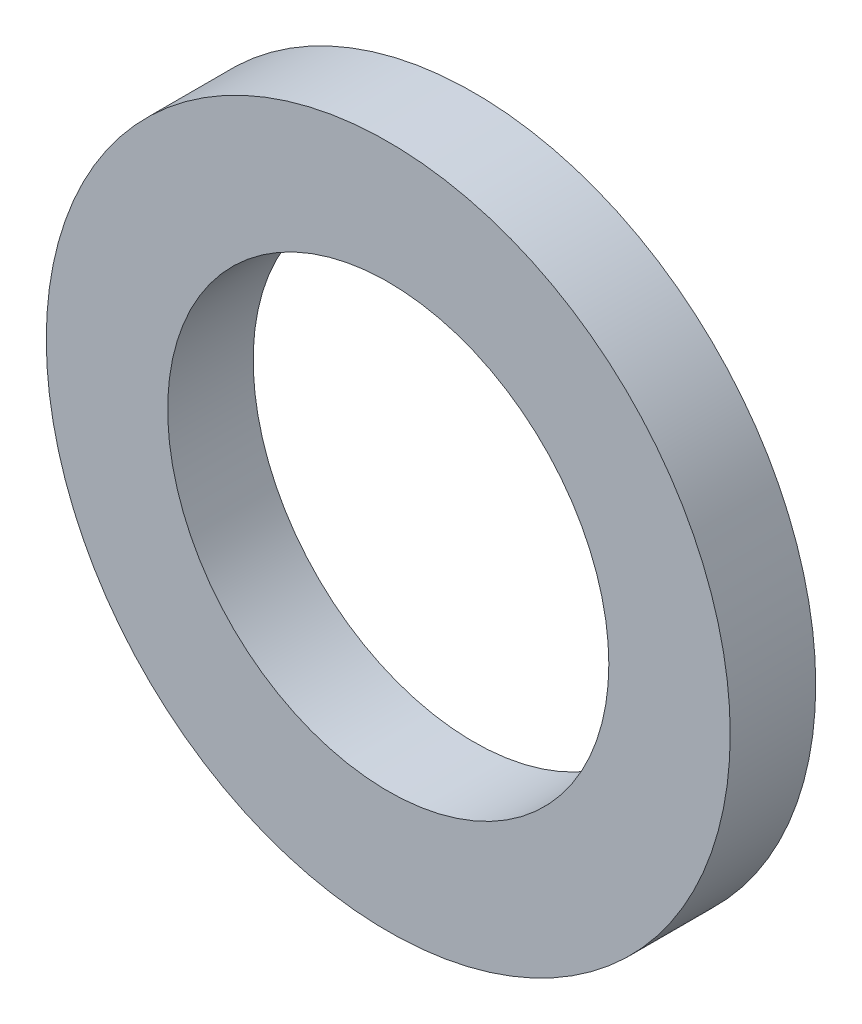
from build123d import *

# Parameters (mm, degrees)
SKETCH1_R      = 6.35
SKETCH1_R_2    = 4.09575
EXTRUDE1_DEPTH = 0.79375


with BuildPart() as part:
    # Sketch1 → Extrude1 (new body, symmetric)
    with BuildSketch(Plane.XY):
        Circle(SKETCH1_R)
        Circle(SKETCH1_R_2, mode=Mode.SUBTRACT)
    extrude(amount=EXTRUDE1_DEPTH, both=True)


solid = part.part
